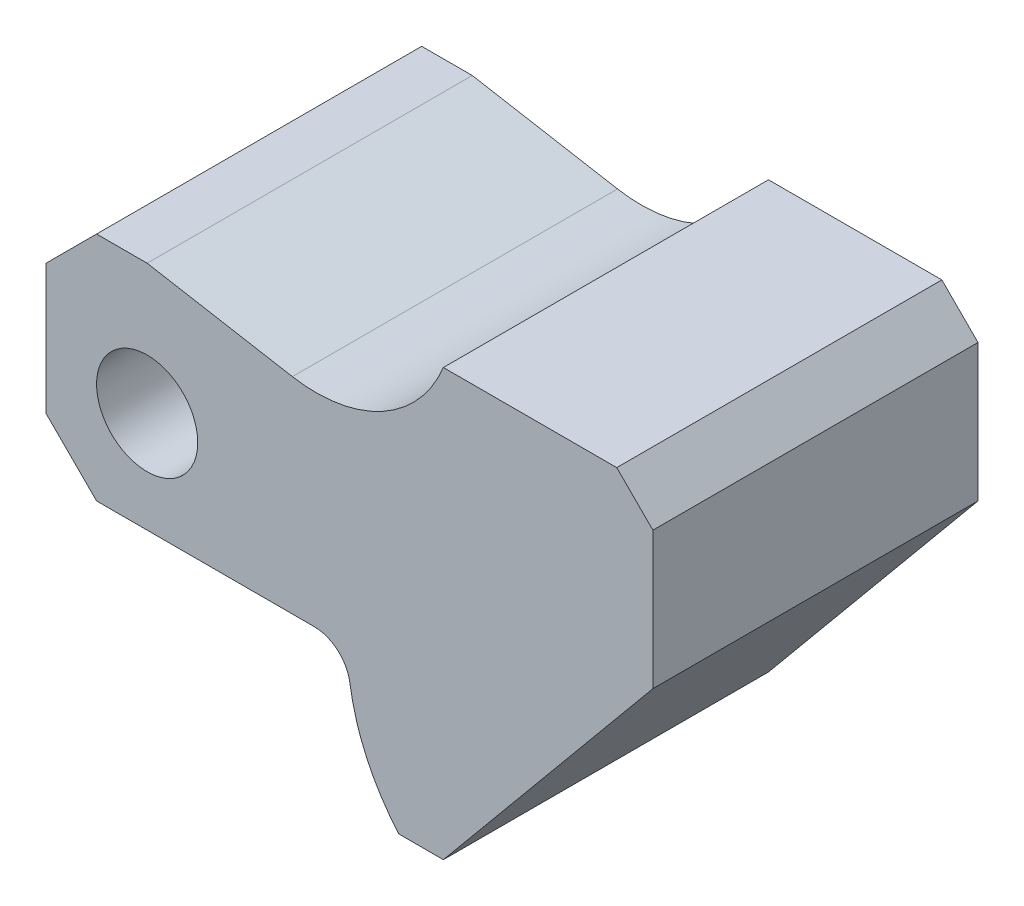
from build123d import *

# Parameters (mm, degrees)
ESQUISSE1_R        = 7
BOSS_EXTRU_1_DEPTH = 45


with BuildPart() as part:
    # Esquisse1 → Boss.-Extru.1 (new body)
    with BuildSketch(Plane.XY):
        with BuildLine():
            Line((0, 0), (29, 35))
            Line((29, 35), (29, 54))
            Line((29, 54), (24, 59))
            Line((24, 59), (0, 59))
            ThreePointArc((0, 59), (-8.408362672, 49.535902458), (-20.895957648, 47.455114912))
            Line((-20.895957648, 47.455114912), (-41, 51))
            Line((-41, 51), (-48, 51))
            Line((-48, 51), (-55, 44))
            Line((-55, 44), (-55, 26))
            Line((-55, 26), (-48, 19))
            Line((-48, 19), (-17.887486299, 19))
            ThreePointArc((-17.887486299, 19), (-14.622250518, 17.786586232), (-12.941847557, 14.735294118))
            ThreePointArc((-12.941847557, 14.735294118), (-10.605017354, 6.884327939), (-6.166045157, 0))
            Line((-6.166045157, 0), (0, 0))
        make_face()
        with Locations((-41, 33)):
            Circle(ESQUISSE1_R, mode=Mode.SUBTRACT)
    extrude(amount=-BOSS_EXTRU_1_DEPTH)


solid = part.part
